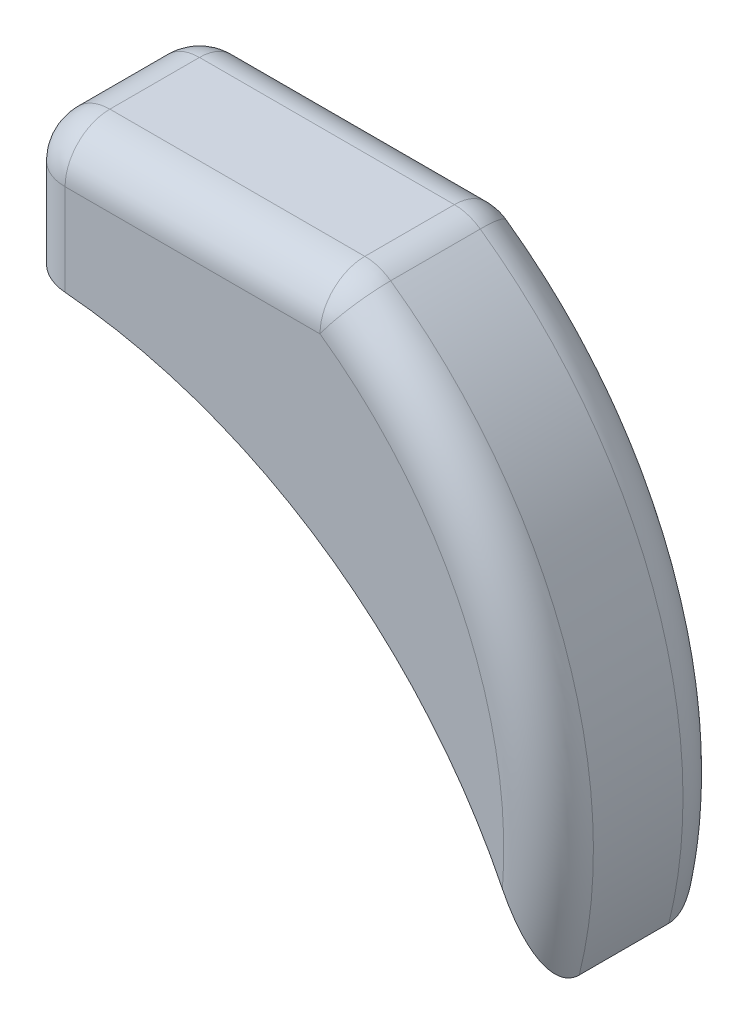
from build123d import *

# Parameters (mm, degrees)
ESQUISSE1_W             = 70
ESQUISSE1_H             = 30
BOSS_EXTRU_1_DEPTH      = 20
CONG_7_R                = 10
ESQUISSE12_R            = 1.25
ENL_V_MAT_EXTRU_5_DEPTH = 15
ESQUISSE11_R            = 1.25
ENL_V_MAT_EXTRU_6_DEPTH = 20


with BuildPart() as part:
    # Esquisse1 → Boss.-Extru.1 (new body, symmetric)
    with BuildSketch(Plane.XY):
        with BuildLine():
            ThreePointArc((79.782402832, -100), (75.641274878, -35.393198769), (35, 15))
            Line((35, 15), (35, -15))
            Line((35, -15), (-35, -15))
            ThreePointArc((-35, -15), (36.414284285, -38.56349239), (79.782402832, -100))
        make_face()
        Rectangle(ESQUISSE1_W, ESQUISSE1_H)
    extrude(amount=BOSS_EXTRU_1_DEPTH, both=True)

    # Congé7
    cong_7_edges = [part.edges().sort_by_distance(p)[0] for p in [
        (-35, 0, 20),
        (75.641274878, -35.393198769, 20),
        (-35, 0, -20),
        (0, 15, -20),
        (75.641274878, -35.393198769, -20),
        (0, 15, 20),
        (-35, 15, 0),
        (35, 15, 0),
    ]]
    fillet(cong_7_edges, radius=CONG_7_R)

    # Esquisse12 → Enlèv. mat.-Extru.5 (cut)
    with BuildSketch(Plane(origin=(0, -18.687162838, 0), x_dir=(1, 0, 0), z_dir=(0, 1, 0))):
        with Locations((-21.600806316, 0)):
            Circle(ESQUISSE12_R)
    extrude(amount=ENL_V_MAT_EXTRU_5_DEPTH, mode=Mode.SUBTRACT)

    # Esquisse11 → Enlèv. mat.-Extru.6 (cut)
    with BuildSketch(Plane(origin=(0, -54.41956978, 0), x_dir=(1, 0, 0), z_dir=(0, 1, 0))):
        with Locations((47.550679202, 0)):
            Circle(ESQUISSE11_R)
    extrude(amount=ENL_V_MAT_EXTRU_6_DEPTH, mode=Mode.SUBTRACT)


solid = part.part
